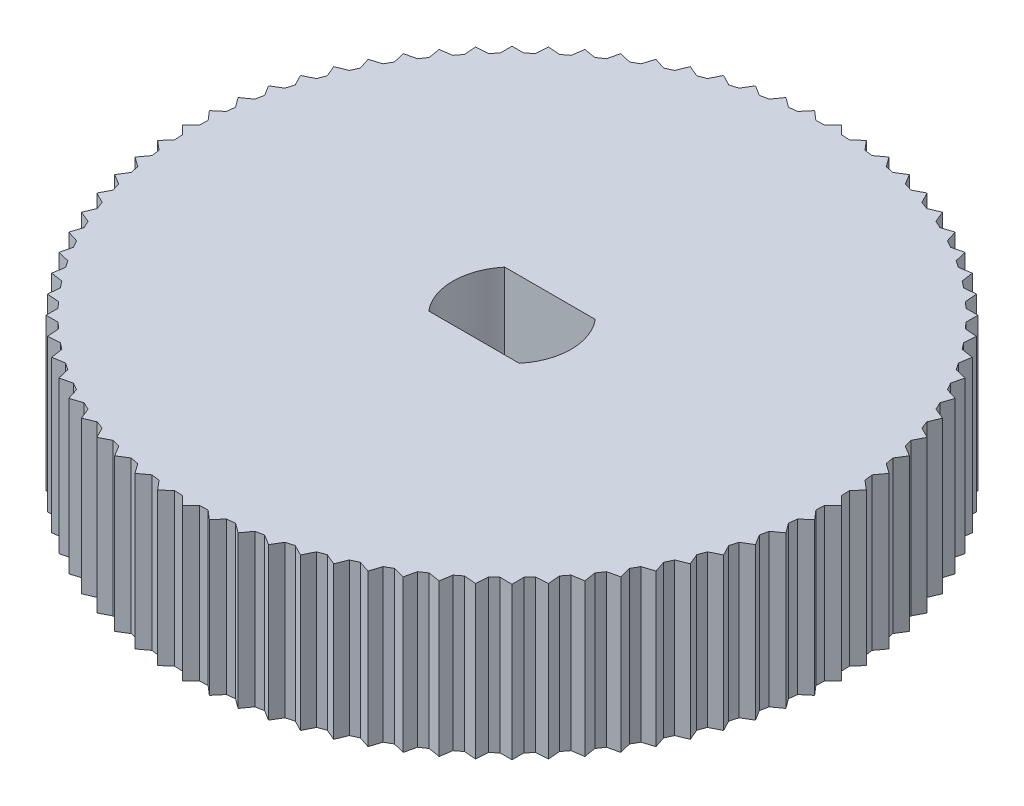
from build123d import *

# Parameters (mm, degrees)
SKETCH1_R           = 19
BOSS_EXTRUDE1_DEPTH = 9
BOSS_EXTRUDE2_DEPTH = 9
CIRPATTERN1_COUNT   = 80


with BuildPart() as part:
    # Sketch1 → Boss-Extrude1 (new body)
    with BuildSketch(Plane(origin=(0, 0, 0), x_dir=(1, 0, 0), z_dir=(0, 1, 0))):
        with Locations(Location((0, 0, 0), (0, 0, 270))):
            Circle(SKETCH1_R)
        with BuildLine():
            Line((-2.67950967, 2.25), (2.67950967, 2.25))
            ThreePointArc((2.67950967, 2.25), (3.498895836, 0), (2.67950967, -2.25))
            Line((2.67950967, -2.25), (-2.67950967, -2.25))
            ThreePointArc((-2.67950967, -2.25), (-3.498895836, 0), (-2.67950967, 2.25))
        make_face(mode=Mode.SUBTRACT)
    extrude(amount=BOSS_EXTRUDE1_DEPTH)

    # Sketch4 → Boss-Extrude2 (add)
    with BuildSketch(Plane(origin=(0, 9, 0), x_dir=(1, 0, 0), z_dir=(0, 1, 0))):
        Polygon((-0.5, 18.993419913), (0, 19.5), (0.5, 18.993419913), align=None)
    boss_extrude2 = extrude(amount=-BOSS_EXTRUDE2_DEPTH)

    # CirPattern1: Boss-Extrude2 ×80 about axis
    cirpattern1_axis = Axis((0, 0, 0), (0, 1, 0))
    for i in range(1, CIRPATTERN1_COUNT):
        add(boss_extrude2.rotate(cirpattern1_axis, i * 360 / CIRPATTERN1_COUNT))


solid = part.part
